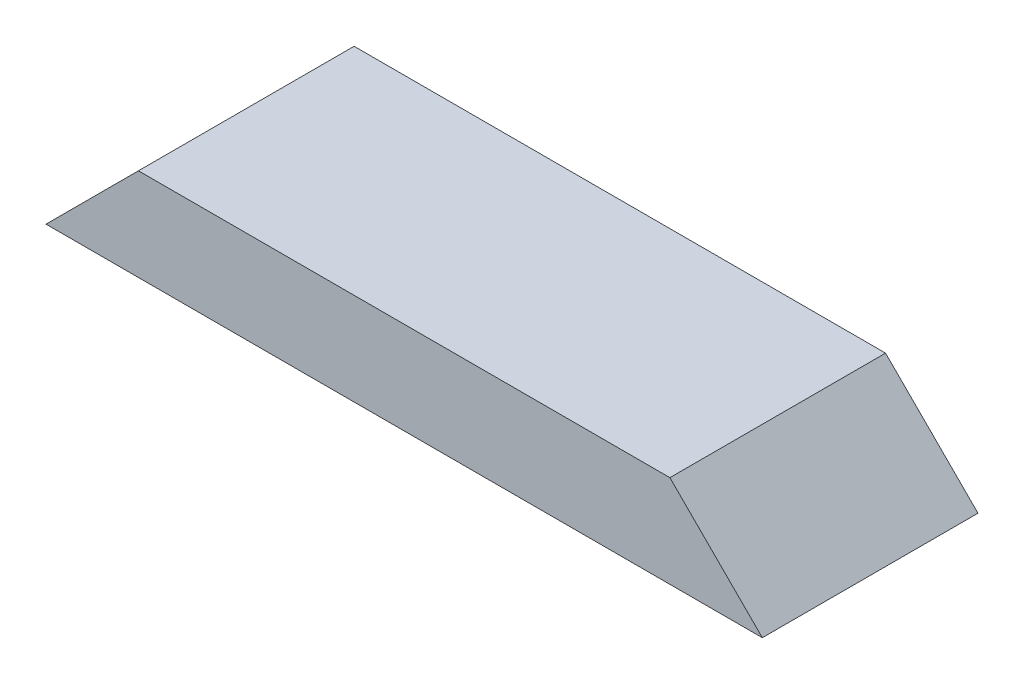
from build123d import *

# Parameters (mm, degrees)
SKETCH1_W           = 295.275
SKETCH1_H           = 88.9
BOSS_EXTRUDE1_DEPTH = 38.1
CUT_EXTRUDE1_DEPTH  = 89.9


with BuildPart() as part:
    # Sketch1 → Boss-Extrude1 (new body)
    with BuildSketch(Plane(origin=(0, 0, 0), x_dir=(1, 0, 0), z_dir=(0, 1, 0))):
        with Locations((147.6375, 44.45)):
            Rectangle(SKETCH1_W, SKETCH1_H)
    extrude(amount=BOSS_EXTRUDE1_DEPTH)

    # Sketch2 → Cut-Extrude1 (cut, through all)
    with BuildSketch(Plane.XY):
        Polygon((0, 0), (38.1, 38.1), (0, 38.1), align=None)
        Polygon((295.275, 0), (295.275, 38.1), (257.175, 38.1), align=None)
    extrude(amount=-CUT_EXTRUDE1_DEPTH, mode=Mode.SUBTRACT)


solid = part.part
